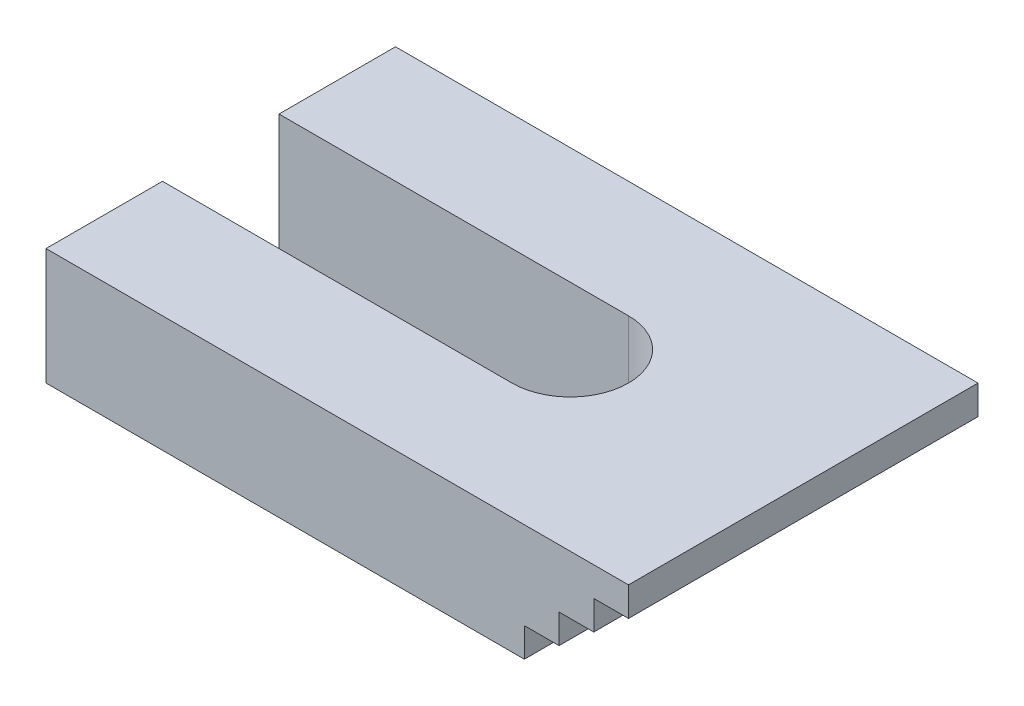
from build123d import *

# Parameters (mm, degrees)
BOSS_EXTRU_1_DEPTH      = 30
ENL_V_MAT_EXTRU_1_DEPTH = 11


with BuildPart() as part:
    # Esquisse1 → Boss.-Extru.1 (new body)
    with BuildSketch(Plane.XY):
        Polygon((-8.475934619, -4.771699816), (-8.475934619, -2.271699816), (-5.496550637, -2.271699816), (-5.496550637, 0.228300184), (-2.517166656, 0.228300184), (-2.517166656, 2.728300184), (0.462833344, 2.728300184), (0.462833344, 5.228300184), (-49.537166656, 5.228300184), (-49.537166656, -4.771699816), align=None)
    extrude(amount=BOSS_EXTRU_1_DEPTH)

    # Esquisse2 → Enlèv. mat.-Extru.1 (cut, through all)
    with BuildSketch(Plane.XZ.offset(4.771699816)):
        with BuildLine():
            Line((-167.240462798, 10), (-49.537166656, 10))
            Line((-49.537166656, 10), (-19.537166656, 10))
            ThreePointArc((-19.537166656, 10), (-14.537166656, 15), (-19.537166656, 20))
            Line((-19.537166656, 20), (-49.537166656, 20))
            Line((-49.537166656, 20), (-167.240462798, 20))
            Line((-167.240462798, 20), (-402.647055084, 20))
            Line((-402.647055084, 20), (-402.647055084, 10))
            Line((-402.647055084, 10), (-167.240462798, 10))
        make_face()
    extrude(amount=-ENL_V_MAT_EXTRU_1_DEPTH, mode=Mode.SUBTRACT)


solid = part.part
